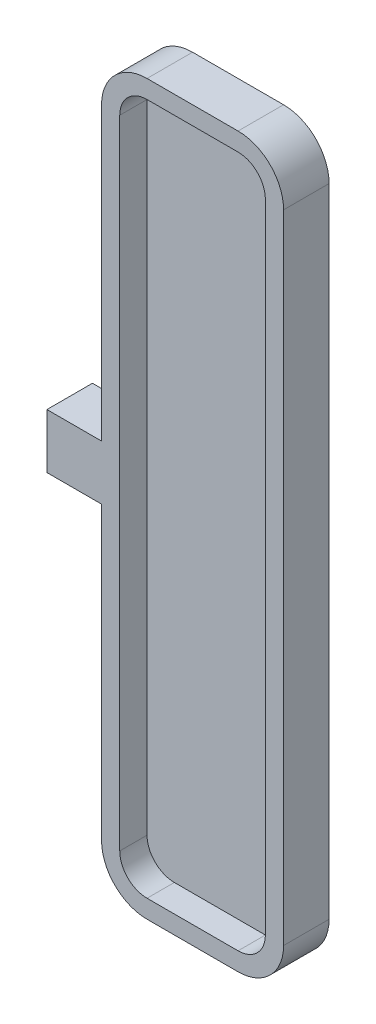
from build123d import *

# Parameters (mm, degrees)
SKETCH1_W           = 20
SKETCH1_H           = 80
BOSS_EXTRUDE1_DEPTH = 5
FILLET1_R           = 5
SHELL2_T            = -2
SKETCH2_W           = 6
SKETCH2_H           = 6
BOSS_EXTRUDE2_DEPTH = 5
SKETCH3_R           = 1.425
CUT_EXTRUDE1_DEPTH  = 4


with BuildPart() as part:
    # Sketch1 → Boss-Extrude1 (new body)
    with BuildSketch(Plane.XY):
        Rectangle(SKETCH1_W, SKETCH1_H)
    extrude(amount=BOSS_EXTRUDE1_DEPTH)

    # Fillet1
    fillet1_edges = [part.edges().sort_by_distance(p)[0] for p in [
        (10, -40, 2.5),
        (-10, -40, 2.5),
        (-10, 40, 2.5),
        (10, 40, 2.5),
    ]]
    fillet(fillet1_edges, radius=FILLET1_R)

    # Shell2
    shell2_openings = [part.faces().sort_by_distance(p)[0] for p in [
        (0, 0, 5),
    ]]
    offset(amount=SHELL2_T, openings=shell2_openings, kind=Kind.INTERSECTION)

    # Sketch2 → Boss-Extrude2 (add)
    with BuildSketch(Plane.XY):
        with Locations((-13, 0)):
            Rectangle(SKETCH2_W, SKETCH2_H)
    extrude(amount=BOSS_EXTRUDE2_DEPTH)

    # Sketch3 → Cut-Extrude1 (cut)
    with BuildSketch(Plane.ZY.offset(16)):
        with Locations((2.5, 0)):
            Circle(SKETCH3_R)
    extrude(amount=-CUT_EXTRUDE1_DEPTH, mode=Mode.SUBTRACT)


solid = part.part
